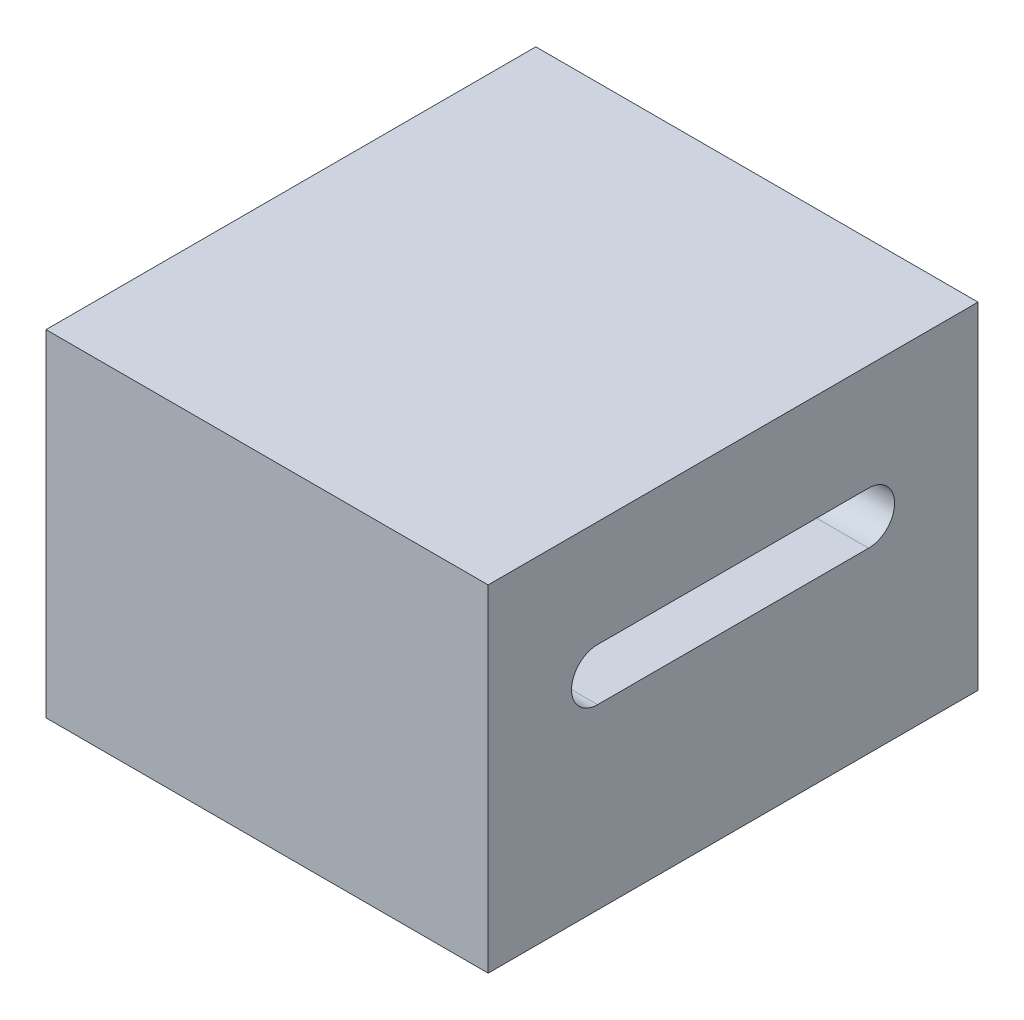
from build123d import *

# Parameters (mm, degrees)
SKETCH1_W           = 42.418
SKETCH1_H           = 46.99
BOSS_EXTRUDE1_DEPTH = 32.258
CUT_EXTRUDE1_DEPTH  = 43.418


with BuildPart() as part:
    # Sketch1 → Boss-Extrude1 (new body)
    with BuildSketch(Plane(origin=(0, 0, 0), x_dir=(1, 0, 0), z_dir=(0, 1, 0))):
        with Locations((21.209, 23.495)):
            Rectangle(SKETCH1_W, SKETCH1_H)
    extrude(amount=BOSS_EXTRUDE1_DEPTH)

    # Sketch2 → Cut-Extrude1 (cut, through all)
    with BuildSketch(Plane(origin=(42.418, 0, 0), x_dir=(0, 0, -1), z_dir=(1, 0, 0))):
        with BuildLine():
            Line((10.495, 22.054113), (36.495, 22.054113))
            ThreePointArc((36.495, 22.054113), (38.991113, 19.558), (36.495, 17.061887))
            Line((36.495, 17.061887), (10.495, 17.061887))
            ThreePointArc((10.495, 17.061887), (7.998887, 19.558), (10.495, 22.054113))
        make_face()
    extrude(amount=-CUT_EXTRUDE1_DEPTH, mode=Mode.SUBTRACT)


solid = part.part
